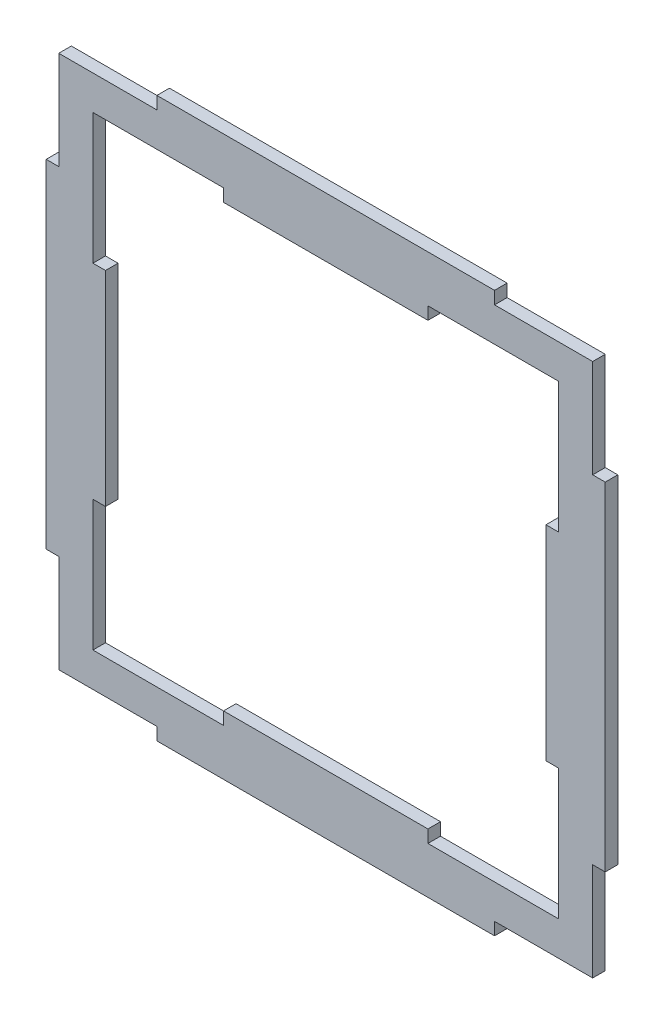
from build123d import *

# Parameters (mm, degrees)
BOSS_EXTRUDE1_DEPTH = 4.6
CUT_EXTRUDE1_DEPTH  = 5.6


with BuildPart() as part:
    # Sketch1 → Boss-Extrude1 (new body)
    with BuildSketch(Plane.XY):
        Polygon((147.4, 61.783577493), (152, 61.783577493), (152, -61.783577493), (147.4, -61.783577493), (147.4, -97.7), (111.483577493, -97.7), (111.483577493, -102.3), (-12.083577493, -102.3), (-12.083577493, -97.7), (-48, -97.7), (-48, -61.783577493), (-52.6, -61.783577493), (-52.6, 61.783577493), (-48, 61.783577493), (-48, 97.7), (-12.083577493, 97.7), (-12.083577493, 102.3), (111.483577493, 102.3), (111.483577493, 97.7), (147.4, 97.7), align=None)
    extrude(amount=BOSS_EXTRUDE1_DEPTH)

    # Sketch2 → Cut-Extrude1 (cut, through all)
    with BuildSketch(Plane(origin=(0, 0, 0), x_dir=(-1, 0, 0), z_dir=(0, 0, -1))):
        Polygon((-134.9, -85.2), (-87.108698535, -85.2), (-87.108698535, -80.6), (-12.291301465, -80.6), (-12.291301465, -85.2), (35.5, -85.2), (35.5, -37.408698535), (30.9, -37.408698535), (30.9, 37.408698535), (35.5, 37.408698535), (35.5, 85.2), (-12.291301465, 85.2), (-12.291301465, 80.6), (-87.108698535, 80.6), (-87.108698535, 85.2), (-134.9, 85.2), (-134.9, 37.408698535), (-130.3, 37.408698535), (-130.3, -37.408698535), (-134.9, -37.408698535), align=None)
    extrude(amount=-CUT_EXTRUDE1_DEPTH, mode=Mode.SUBTRACT)


solid = part.part
